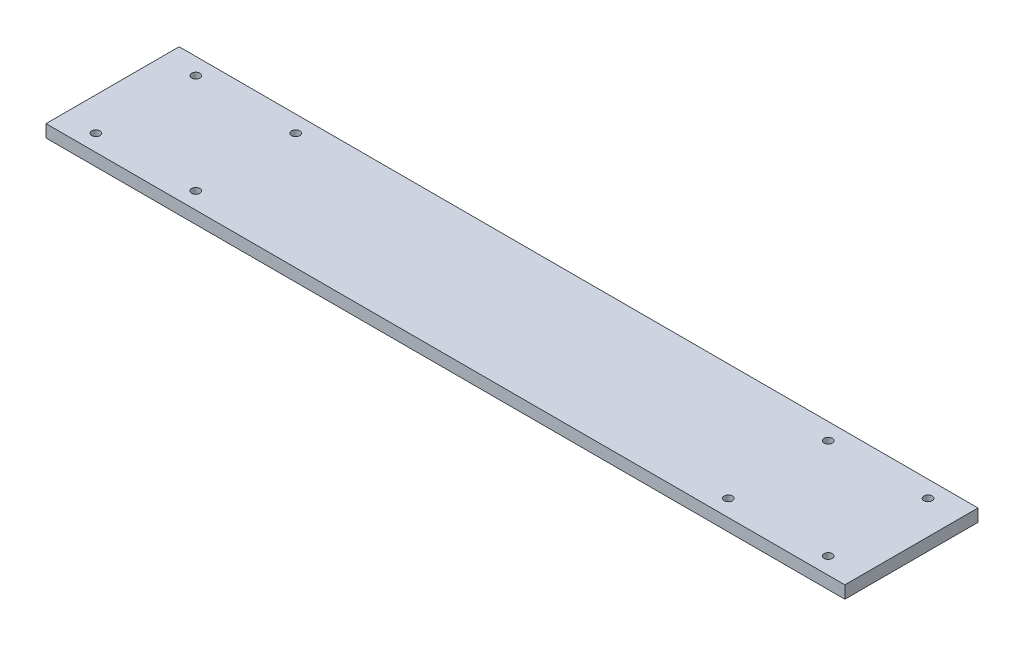
from build123d import *

# Parameters (mm, degrees)
SKETCH1_W                   = 609.6
SKETCH1_H                   = 101.6
BOSS_EXTRUDE1_DEPTH         = 9.525
F_1_4_0_25_DIAMETER_HOLE1_D = 6.35


with BuildPart() as part:
    # Sketch1 → Boss-Extrude1 (new body)
    with BuildSketch(Plane(origin=(0, 0, 0), x_dir=(1, 0, 0), z_dir=(0, 1, 0))):
        Rectangle(SKETCH1_W, SKETCH1_H)
    extrude(amount=BOSS_EXTRUDE1_DEPTH)

    # 1/4 (0.25) Diameter Hole1 (through all)
    with Locations(Plane(origin=(0, 9.525, 0), x_dir=(1, 0, 0), z_dir=(0, 1, 0))):
        with Locations((279.4, -38.1), (279.4, 38.1), (203.2, 38.1), (203.2, -38.1), (-203.2, -38.1), (-279.4, -38.1), (-279.4, 38.1), (-203.2, 38.1)):
            Hole(F_1_4_0_25_DIAMETER_HOLE1_D / 2)


solid = part.part
